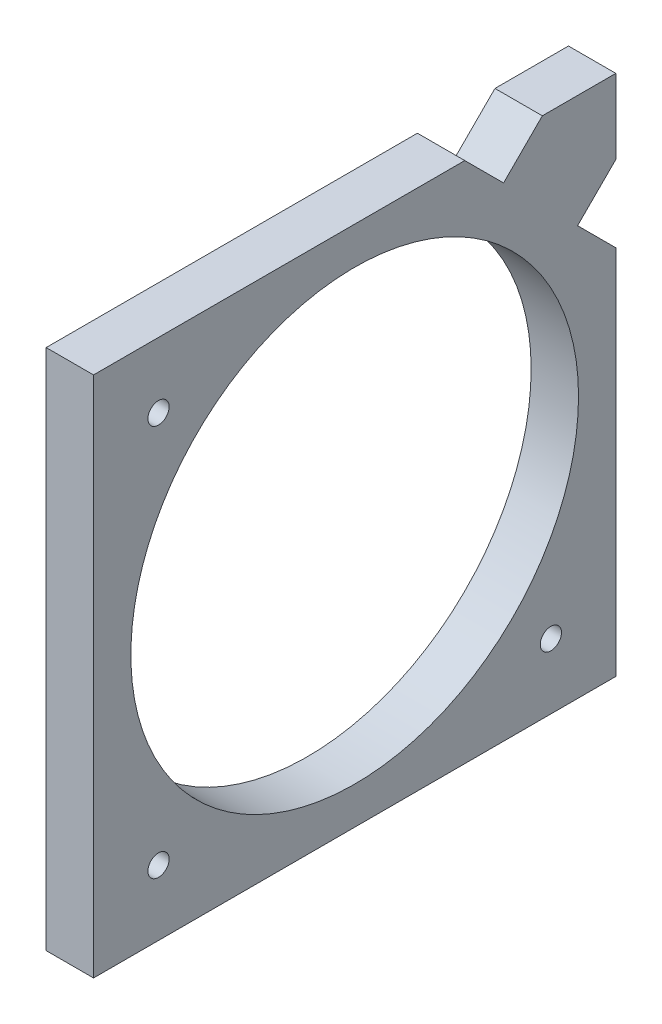
from build123d import *

# Parameters (mm, degrees)
SKETCH1_R           = 30
BOSS_EXTRUDE1_DEPTH = 6.35
SKETCH2_R           = 1.4224
CUT_EXTRUDE1_DEPTH  = 6.35


with BuildPart() as part:
    # Sketch1 → Boss-Extrude1 (new body)
    with BuildSketch(Plane(origin=(0, 0, 0), x_dir=(0, 0, -1), z_dir=(1, 0, 0))):
        Polygon((0, 0), (70, 0), (70, 49.756615014), (64.872483647, 54.884131367), (70, 60.011647719), (70, 70), (60.148635267, 70), (54.952625141, 64.803989874), (49.756615014, 70), (0, 70), align=None)
        with Locations((35, 35)):
            Circle(SKETCH1_R, mode=Mode.SUBTRACT)
    extrude(amount=BOSS_EXTRUDE1_DEPTH)

    # Sketch2 → Cut-Extrude1 (cut)
    with BuildSketch(Plane(origin=(6.35, 0, 0), x_dir=(0, 0, -1), z_dir=(1, 0, 0))):
        with Locations((8.707441752, 61.25)):
            Circle(SKETCH2_R)
        with Locations((8.707441752, 8.75)):
            Circle(SKETCH2_R)
        with Locations((61.292558248, 8.75)):
            Circle(SKETCH2_R)
    extrude(amount=-CUT_EXTRUDE1_DEPTH, mode=Mode.SUBTRACT)


solid = part.part
